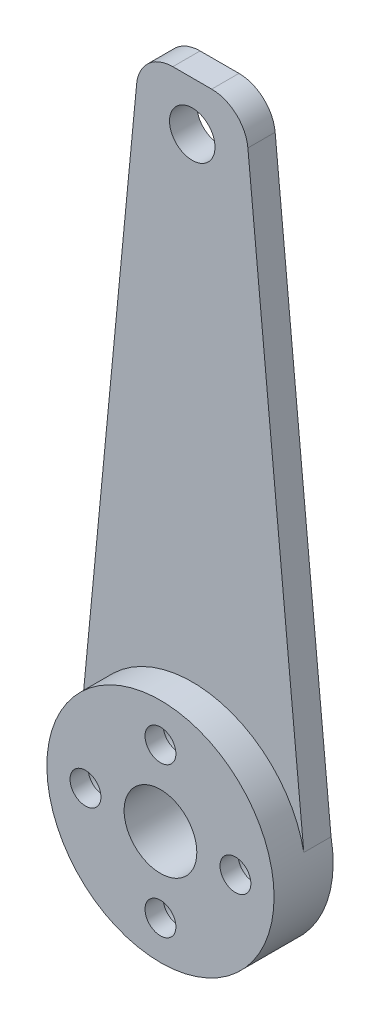
from build123d import *

# Parameters (mm, degrees)
ESQUISSE2_R                  = 12.5
BOSS_EXTRU_1_DEPTH           = 3.25
ESQUISSE3_R                  = 1.2
ENL_V_MAT_EXTRU_1_DEPTH      = 4.25
BOSS_EXTRU_2_DEPTH           = 3
ESQUISSE10_R                 = 1.7
ENL_V_MAT_EXTRU_2_DEPTH      = 1
ENL_V_MAT_EXTRU_2_DEPTH_BACK = 7.5
ESQUISSE17_R                 = 4
ENL_V_MAT_EXTRU_8_DEPTH      = 7.5
CONG_1_R                     = 4
ESQUISSE21_R                 = 2.5
ENL_V_MAT_EXTRU_9_DEPTH      = 7.5
SKETCH2_R                    = 2.75
CUT_EXTRUDE2_DEPTH           = 4.5


with BuildPart() as part:
    # Esquisse2 → Boss.-Extru.1 (new body, symmetric)
    with BuildSketch(Plane.XY):
        Circle(ESQUISSE2_R)
    extrude(amount=BOSS_EXTRU_1_DEPTH, both=True)

    # Esquisse3 → Enlèv. mat.-Extru.1 (cut, through all)
    with BuildSketch(Plane.XY):
        with Locations((0, 8.25)):
            Circle(ESQUISSE3_R)
        with Locations((-8.25, 0)):
            Circle(ESQUISSE3_R)
        with Locations((0, -8.25)):
            Circle(ESQUISSE3_R)
        with Locations((8.25, 0)):
            Circle(ESQUISSE3_R)
    extrude(amount=ENL_V_MAT_EXTRU_1_DEPTH, mode=Mode.SUBTRACT)

    # Esquisse20 → Boss.-Extru.2 (add)
    with BuildSketch(Plane(origin=(0, 0, -3.25), x_dir=(-1, 0, 0), z_dir=(0, 0, -1))):
        Polygon((-12.5, 0), (-5.772196938, 70.05324764), (5.772196938, 70.05324764), (12.5, 0), align=None)
    extrude(amount=-BOSS_EXTRU_2_DEPTH)

    # Esquisse10 → Enlèv. mat.-Extru.2 (cut, two sides)
    with BuildSketch(Plane(origin=(0, 0, -3.25), x_dir=(-1, 0, 0), z_dir=(0, 0, -1))) as enl_v_mat_extru_2_sk:
        with Locations((-8.25, 0)):
            Circle(ESQUISSE10_R)
        with Locations((0, 8.25)):
            Circle(ESQUISSE10_R)
        with Locations((8.25, 0)):
            Circle(ESQUISSE10_R)
        with Locations((0, -8.25)):
            Circle(ESQUISSE10_R)
    extrude(amount=ENL_V_MAT_EXTRU_2_DEPTH, mode=Mode.SUBTRACT)
    extrude(enl_v_mat_extru_2_sk.sketch, amount=-ENL_V_MAT_EXTRU_2_DEPTH_BACK, mode=Mode.SUBTRACT)

    # Esquisse17 → Enlèv. mat.-Extru.8 (cut, through all)
    with BuildSketch(Plane.XY.offset(3.25)):
        Circle(ESQUISSE17_R)
    extrude(amount=-ENL_V_MAT_EXTRU_8_DEPTH, mode=Mode.SUBTRACT)

    # Congé1
    cong_1_edges = [part.edges().sort_by_distance(p)[0] for p in [
        (-5.772196938, 70.05324764, -1.75),
        (5.772196938, 70.05324764, -1.75),
    ]]
    fillet(cong_1_edges, radius=CONG_1_R)

    # Esquisse21 → Enlèv. mat.-Extru.9 (cut, through all)
    with BuildSketch(Plane(origin=(0, 0, -3.25), x_dir=(-1, 0, 0), z_dir=(0, 0, -1))):
        with Locations((0, 64.696529063)):
            Circle(ESQUISSE21_R)
    extrude(amount=-ENL_V_MAT_EXTRU_9_DEPTH, mode=Mode.SUBTRACT)

    # Sketch2 → Cut-Extrude2 (cut)
    with BuildSketch(Plane(origin=(0, 0, -3.25), x_dir=(-1, 0, 0), z_dir=(0, 0, -1))):
        with Locations((0, 8.25)):
            Circle(SKETCH2_R)
        with Locations((8.25, 0)):
            Circle(SKETCH2_R)
        with Locations((-8.25, 0)):
            Circle(SKETCH2_R)
        with Locations((0, -8.25)):
            Circle(SKETCH2_R)
    extrude(amount=-CUT_EXTRUDE2_DEPTH, mode=Mode.SUBTRACT)


solid = part.part
